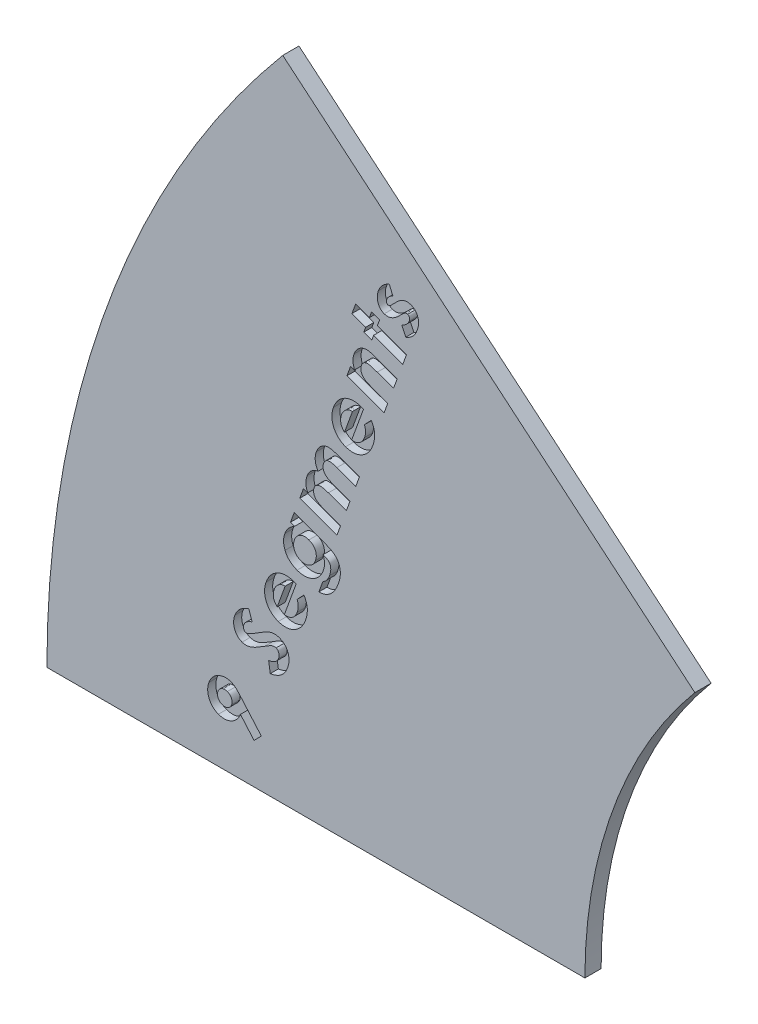
from build123d import *

# Parameters (mm, degrees)
BOSS_EXTRUDE1_DEPTH = 3.175
CUT_EXTRUDE1_DEPTH  = 1.5875


with BuildPart() as part:
    # Sketch2 → Boss-Extrude1 (new body)
    with BuildSketch(Plane.XY):
        with BuildLine():
            Line((0, 0), (105.445292337, 0))
            ThreePointArc((105.445292337, 0), (111.001509707, 31.510874554), (127, 59.221072586))
            Line((127, 59.221072586), (46.224219752, 127))
            ThreePointArc((46.224219752, 127), (11.915346601, 67.575288552), (0, 0))
        make_face()
    extrude(amount=BOSS_EXTRUDE1_DEPTH)

    # Sketch3 → Cut-Extrude1 (cut)
    with BuildSketch(Plane.XY.offset(3.175)):
        with BuildLine():
            Line((42.016640282, 9.353258219), (40.594080854, 7.907378144))
            Line((40.594080854, 7.907378144), (37.929166991, 10.998423817))
            add(Edge.make_bspline(
                [(37.929166991, 10.998423817), (37.885853294, 10.888052491), (37.800373976, 10.670235353), (37.640916121, 10.362599517), (37.457053629, 10.078450819), (37.251121295, 9.816696228), (37.021085541, 9.57706123), (36.76475112, 9.363872684), (36.489120282, 9.168725945), (36.190861614, 9.00395088), (35.882115791, 8.862940332), (35.565303011, 8.75964719), (35.246619215, 8.688348741), (34.924652519, 8.651588221), (34.599030785, 8.652339189), (34.271074005, 8.687073033), (33.940022624, 8.753610882), (33.724410797, 8.826490691), (33.614847413, 8.863524645)],
                knots=[0, 0, 0, 0, 1.060142226, 2.092184197, 3.093464805, 4.083768351, 5.067390293, 6.058964299, 7.062159022, 8.083926241, 9.10261829, 10.094212449, 11.059004012, 12.019644129, 12.986897348, 13.965712959, 14.96627483, 16, 16, 16, 16], degree=3))
            add(Edge.make_bspline(
                [(33.614847413, 8.863524645), (33.509909072, 8.905054064), (33.303708371, 8.98665813), (33.015851438, 9.147038077), (32.748546487, 9.328009847), (32.509117873, 9.540469163), (32.289216607, 9.774993556), (32.09790083, 10.039326863), (31.926293982, 10.327577576), (31.782497061, 10.639302618), (31.664263966, 10.96388452), (31.578992669, 11.295522547), (31.524782767, 11.629063243), (31.50732832, 11.96569384), (31.516436512, 12.305070161), (31.562591108, 12.646197659), (31.637906157, 12.990945727), (31.714461397, 13.21594227), (31.753435822, 13.330488454)],
                knots=[0, 0, 0, 0, 1.005324294, 1.975432156, 2.931522168, 3.878200568, 4.8234938, 5.79270076, 6.781537987, 7.810519289, 8.84902662, 9.857741961, 10.859525012, 11.85675931, 12.85917635, 13.882294683, 14.92187205, 16, 16, 16, 16], degree=3))
            add(Edge.make_bspline(
                [(31.753435822, 13.330488454), (31.799436173, 13.447986083), (31.889820439, 13.678852514), (32.058190472, 14.004020708), (32.250598507, 14.302919462), (32.463993268, 14.577786905), (32.704218665, 14.824831167), (32.964786943, 15.048908391), (33.251277415, 15.244424513), (33.55632997, 15.412318188), (33.872464727, 15.550899032), (34.189603596, 15.660674147), (34.506136651, 15.732794343), (34.819163255, 15.773413086), (35.130594906, 15.78368134), (35.438813247, 15.754092954), (35.745778467, 15.696226726), (35.94400992, 15.630253543), (36.044434753, 15.596831269)],
                knots=[0, 0, 0, 0, 1.123558795, 2.207636099, 3.255458764, 4.286925767, 5.302085954, 6.320248139, 7.34357485, 8.386183254, 9.417919214, 10.415374452, 11.371417735, 12.304592384, 13.2241177, 14.140663916, 15.058053032, 16, 16, 16, 16], degree=3))
            add(Edge.make_bspline(
                [(36.044434753, 15.596831269), (36.119931662, 15.567796927), (36.270991801, 15.509702737), (36.489011915, 15.397136905), (36.699803876, 15.266097405), (36.871922448, 15.140573104), (37.013198151, 15.02465813), (37.13166885, 14.918925881), (37.259232846, 14.793349334), (37.401530288, 14.653557778), (37.549403178, 14.49130639), (37.714380922, 14.316179344), (37.887804925, 14.120666964), (38.005707029, 13.982946346), (38.066970811, 13.911384554)],
                knots=[0, 0, 0, 0, 1.091979601, 2.184918487, 3.30812201, 4.442305933, 5.05956538, 5.776225361, 6.586354439, 7.47737268, 8.47021682, 9.550998054, 10.727460196, 12, 12, 12, 12], degree=3))
            Line((38.066970811, 13.911384554), (42.016640282, 9.353258219))
        make_face()
        with BuildLine():
            add(Edge.make_bspline(
                [(36.199199043, 11.759524912), (36.228657185, 11.852668486), (36.285975363, 12.033902592), (36.30329388, 12.316656177), (36.268021767, 12.593259115), (36.172123254, 12.856648993), (36.03594766, 13.100426231), (35.850048383, 13.305844901), (35.626631627, 13.474734378), (35.452822042, 13.546207614), (35.363895891, 13.582775446)],
                knots=[0, 0, 0, 0, 1.045045202, 2.033396657, 3.012743776, 4.01783249, 5.023493383, 5.990337497, 6.971796924, 8, 8, 8, 8], degree=3))
            add(Edge.make_bspline(
                [(35.363895891, 13.582775446), (35.269375692, 13.612592235), (35.085430825, 13.670618406), (34.797628893, 13.682942264), (34.516082016, 13.640636353), (34.247940492, 13.537600332), (34.003370257, 13.39133848), (33.79538307, 13.205227362), (33.626767978, 12.984536852), (33.555485711, 12.814409601), (33.519444769, 12.728391766)],
                knots=[0, 0, 0, 0, 1.049889721, 2.043180471, 3.031541709, 4.058786779, 5.076866243, 6.045375139, 7.011724462, 8, 8, 8, 8], degree=3))
            add(Edge.make_bspline(
                [(33.519444769, 12.728391766), (33.491150103, 12.635188238), (33.435415149, 12.451595535), (33.414160546, 12.164872727), (33.452653423, 11.881750564), (33.540413494, 11.607926075), (33.678679054, 11.35575292), (33.86573843, 11.141553473), (34.093902993, 10.965954117), (34.27207089, 10.892064483), (34.363228156, 10.854259821)],
                knots=[0, 0, 0, 0, 1.019895558, 2.008994586, 2.98862379, 4.001756578, 5.010891699, 5.983393364, 6.968229675, 8, 8, 8, 8], degree=3))
            add(Edge.make_bspline(
                [(34.363228156, 10.854259821), (34.456394513, 10.825545158), (34.637793974, 10.769636303), (34.920736925, 10.753858956), (35.19762686, 10.794039152), (35.462098006, 10.895749164), (35.705651974, 11.044876979), (35.915105225, 11.241453637), (36.084722562, 11.481951649), (36.160281993, 11.665162014), (36.199199043, 11.759524912)],
                knots=[0, 0, 0, 0, 1.020023146, 1.986035024, 2.945791188, 3.936264358, 4.938662057, 5.925128351, 6.931332828, 8, 8, 8, 8], degree=3))
        make_face(mode=Mode.SUBTRACT)
        with BuildLine():
            Line((39.540130815, 29.786140957), (40.216429559, 27.83144678))
            add(Edge.make_bspline(
                [(40.216429559, 27.83144678), (40.11199429, 27.795471087), (39.911810136, 27.726511972), (39.630983878, 27.603156586), (39.383022339, 27.465503807), (39.163483258, 27.316935746), (38.976312636, 27.154335959), (38.82080389, 26.977675751), (38.695280761, 26.789120032), (38.637781835, 26.652318707), (38.609425019, 26.584852229)],
                knots=[0, 0, 0, 0, 1.259249042, 2.413760288, 3.492341546, 4.489258686, 5.431557168, 6.310935981, 7.167002213, 8, 8, 8, 8], degree=3))
            add(Edge.make_bspline(
                [(38.609425019, 26.584852229), (38.588203781, 26.520364373), (38.547325167, 26.396140982), (38.522521021, 26.206864192), (38.525038738, 26.026129965), (38.561027017, 25.85814419), (38.621489249, 25.710337042), (38.700909257, 25.587726466), (38.799025407, 25.491494366), (38.879441038, 25.45555795), (38.918953598, 25.437900439)],
                knots=[0, 0, 0, 0, 1.242797265, 2.394008739, 3.483124416, 4.543237651, 5.525359634, 6.395359241, 7.211552972, 8, 8, 8, 8], degree=3))
            add(Edge.make_bspline(
                [(38.918953598, 25.437900439), (38.961039688, 25.425639308), (39.04540398, 25.401061077), (39.179350266, 25.394137423), (39.317703919, 25.408759618), (39.408325764, 25.436324009), (39.455328464, 25.450620792)],
                knots=[0, 0, 0, 0, 0.959855315, 1.924092125, 2.923291887, 4, 4, 4, 4], degree=3))
            add(Edge.make_bspline(
                [(39.455328464, 25.450620792), (39.492969316, 25.465743354), (39.580188932, 25.500784647), (39.724759362, 25.572677772), (39.90113932, 25.668574699), (40.112282851, 25.784473583), (40.352706165, 25.928542017), (40.629391718, 26.090218186), (40.935842979, 26.279838444), (41.150737961, 26.414433728), (41.263738587, 26.485209467)],
                knots=[0, 0, 0, 0, 0.466706266, 1.081429856, 1.85645288, 2.777524465, 3.852950597, 5.081778915, 6.465479248, 8, 8, 8, 8], degree=3))
            add(Edge.make_bspline(
                [(41.263738587, 26.485209467), (41.368224427, 26.551802526), (41.56695991, 26.678464702), (41.850805086, 26.855815382), (42.103221578, 27.01364323), (42.325097476, 27.148219441), (42.515106963, 27.263560089), (42.672568188, 27.358960927), (42.800294388, 27.43225247), (42.876280585, 27.471252954), (42.908904185, 27.487997261)],
                knots=[0, 0, 0, 0, 1.543054767, 2.934940615, 4.168235638, 5.25046588, 6.166652502, 6.936420986, 7.543367375, 8, 8, 8, 8], degree=3))
            add(Edge.make_bspline(
                [(42.908904185, 27.487997261), (43.038158081, 27.550445552), (43.285475014, 27.669935334), (43.652006682, 27.814791072), (43.997740537, 27.910478319), (44.323557173, 27.969375717), (44.639839936, 27.983644646), (44.951924246, 27.962081429), (45.265666436, 27.905804603), (45.468511082, 27.838250655), (45.571697989, 27.803886016)],
                knots=[0, 0, 0, 0, 1.244426712, 2.38111042, 3.411264158, 4.350053435, 5.24562082, 6.148369224, 7.058076926, 8, 8, 8, 8], degree=3))
            add(Edge.make_bspline(
                [(45.571697989, 27.803886016), (45.66950539, 27.76579356), (45.862003216, 27.690822597), (46.129793772, 27.542254847), (46.375427075, 27.372419433), (46.597411915, 27.178271927), (46.795503488, 26.960471073), (46.971373681, 26.719657777), (47.118658808, 26.451924091), (47.245495962, 26.165753111), (47.345333044, 25.863449164), (47.412684971, 25.549931501), (47.451509266, 25.228445023), (47.457466496, 24.898210939), (47.430836086, 24.559934661), (47.37539567, 24.213170998), (47.288647509, 23.857709799), (47.207483896, 23.622538092), (47.165982177, 23.502286791)],
                knots=[0, 0, 0, 0, 0.979291508, 1.927374458, 2.851919103, 3.763941763, 4.674913154, 5.596343256, 6.541850014, 7.522874586, 8.51629674, 9.50917069, 10.512778253, 11.535920654, 12.588254492, 13.677602042, 14.812478839, 16, 16, 16, 16], degree=3))
            add(Edge.make_bspline(
                [(47.165982177, 23.502286791), (47.130293398, 23.409275086), (47.059711607, 23.225325598), (46.936991399, 22.960928768), (46.800824489, 22.711745196), (46.652159182, 22.477975125), (46.490904205, 22.258267783), (46.315128443, 22.055464634), (46.126821056, 21.867639134), (45.927407631, 21.692782316), (45.713062668, 21.533227866), (45.481786666, 21.390747639), (45.235581484, 21.262086236), (44.975166521, 21.144374145), (44.697283605, 21.045649174), (44.405186747, 20.958675446), (44.096613343, 20.885845568), (43.884371812, 20.850949568), (43.776008218, 20.833132811)],
                knots=[0, 0, 0, 0, 1.048014307, 2.072660601, 3.064291067, 4.033790116, 4.9855911, 5.929224471, 6.85460551, 7.782134993, 8.71755899, 9.662597537, 10.637130615, 11.638995355, 12.66687415, 13.73733354, 14.844756408, 16, 16, 16, 16], degree=3))
            Line((43.776008218, 20.833132811), (43.449519169, 22.891709868))
            add(Edge.make_bspline(
                [(43.449519169, 22.891709868), (43.575900632, 22.917620493), (43.81861374, 22.967381338), (44.158958454, 23.076672022), (44.462960265, 23.204498804), (44.728151371, 23.357491078), (44.955872537, 23.53276474), (45.147693679, 23.728560353), (45.30042987, 23.950083788), (45.36813642, 24.11355852), (45.402093288, 24.195546005)],
                knots=[0, 0, 0, 0, 1.25802725, 2.416016549, 3.481716423, 4.470460391, 5.394574196, 6.2772384, 7.135983337, 8, 8, 8, 8], degree=3))
            add(Edge.make_bspline(
                [(45.402093288, 24.195546005), (45.429590031, 24.281072798), (45.482856501, 24.446754619), (45.515310281, 24.700719702), (45.502909195, 24.946370794), (45.447192582, 25.177368015), (45.361279689, 25.386141926), (45.243882851, 25.559536013), (45.097733745, 25.695519303), (44.979988405, 25.747005855), (44.920839949, 25.772869723)],
                knots=[0, 0, 0, 0, 1.18285366, 2.291414673, 3.355318235, 4.408720333, 5.410955289, 6.315723653, 7.153916876, 8, 8, 8, 8], degree=3))
            add(Edge.make_bspline(
                [(44.920839949, 25.772869723), (44.864079127, 25.790353483), (44.747564098, 25.826243039), (44.558134286, 25.830066642), (44.358181049, 25.806756258), (44.183899155, 25.757630313), (44.030851539, 25.699150229), (43.895908415, 25.636322956), (43.740021423, 25.560601883), (43.567925113, 25.464409273), (43.376742268, 25.353592696), (43.165730706, 25.228863145), (42.938447132, 25.084454013), (42.780904653, 24.982223152), (42.699018368, 24.929086337)],
                knots=[0, 0, 0, 0, 0.867842592, 1.78145243, 2.752699461, 3.816950524, 4.42753279, 5.156254102, 6.000410368, 6.970493863, 8.048502387, 9.243760348, 10.567381771, 12, 12, 12, 12], degree=3))
            add(Edge.make_bspline(
                [(42.699018368, 24.929086337), (42.542574916, 24.828035039), (42.241962247, 24.633860722), (41.802581516, 24.365770733), (41.399164769, 24.12482977), (41.027145327, 23.918645613), (40.688313884, 23.743427894), (40.38072184, 23.602075147), (40.107920141, 23.486250142), (39.861065467, 23.406915462), (39.63438951, 23.349498433), (39.41811405, 23.312070176), (39.207895386, 23.287376804), (39.003729913, 23.281758449), (38.805092417, 23.289077797), (38.612446773, 23.31553308), (38.424474584, 23.354123838), (38.304486761, 23.39501495), (38.244774912, 23.415364382)],
                knots=[0, 0, 0, 0, 1.835047382, 3.526120678, 5.071448161, 6.464707309, 7.716637059, 8.828898001, 9.80002765, 10.63461198, 11.381086898, 12.102321897, 12.795934574, 13.464741248, 14.112930305, 14.752079676, 15.378973397, 16, 16, 16, 16], degree=3))
            add(Edge.make_bspline(
                [(38.244774912, 23.415364382), (38.161793105, 23.447865505), (37.997646975, 23.512155907), (37.770807017, 23.645060963), (37.558052641, 23.794694339), (37.367677125, 23.972498057), (37.194220963, 24.170848138), (37.041061186, 24.392992035), (36.907766336, 24.638797071), (36.792023902, 24.903755412), (36.69897367, 25.182361621), (36.635963222, 25.469602733), (36.59620158, 25.75962822), (36.58952015, 26.055037164), (36.605542222, 26.353764797), (36.651319301, 26.656512155), (36.722793191, 26.963171749), (36.791489659, 27.164855677), (36.826455601, 27.26751115)],
                knots=[0, 0, 0, 0, 0.936448395, 1.852386499, 2.758368459, 3.668825935, 4.585970809, 5.526632219, 6.501760602, 7.524148564, 8.56593373, 9.587103903, 10.614671551, 11.641350801, 12.691595158, 13.759074909, 14.859387433, 16, 16, 16, 16], degree=3))
            add(Edge.make_bspline(
                [(36.826455601, 27.26751115), (36.878467952, 27.398289994), (36.981882506, 27.658313544), (37.192058771, 28.022017277), (37.435534199, 28.362796674), (37.672269929, 28.625069393), (37.886061853, 28.821964994), (38.066952956, 28.968057225), (38.265755285, 29.111808792), (38.484329996, 29.252264888), (38.720284566, 29.391334414), (38.97588081, 29.528094771), (39.251789626, 29.657827476), (39.44245465, 29.742674505), (39.540130815, 29.786140957)],
                knots=[0, 0, 0, 0, 1.324407864, 2.633279368, 3.945110688, 5.264908753, 5.952810712, 6.681696361, 7.454100858, 8.262946113, 9.12844321, 10.033886327, 10.992775721, 12, 12, 12, 12], degree=3))
        make_face()
        with BuildLine():
            Line((48.859189563, 38.611004947), (46.533485103, 32.221147842))
            add(Edge.make_bspline(
                [(46.533485103, 32.221147842), (46.601183558, 32.210576043), (46.735328169, 32.189628003), (46.936324255, 32.18276878), (47.132249892, 32.189905597), (47.323308142, 32.218160345), (47.509215991, 32.264756833), (47.690691869, 32.329135041), (47.867923595, 32.409730386), (48.039119426, 32.510017999), (48.20390715, 32.625233634), (48.357837318, 32.75886967), (48.502117479, 32.906327559), (48.633203567, 33.071894202), (48.757965891, 33.249404225), (48.866271732, 33.446407461), (48.969976019, 33.65531628), (49.025816757, 33.803580068), (49.054234969, 33.879033793)],
                knots=[0, 0, 0, 0, 0.994573682, 1.970749532, 2.916154219, 3.839563181, 4.77081464, 5.696218932, 6.633393545, 7.594827866, 8.574667891, 9.55014167, 10.552053531, 11.566978119, 12.614959783, 13.699904295, 14.829445872, 16, 16, 16, 16], degree=3))
            add(Edge.make_bspline(
                [(49.054234969, 33.879033793), (49.08580358, 33.971068484), (49.147937344, 34.1522124), (49.207614525, 34.430495893), (49.247582788, 34.705964393), (49.258384911, 34.980978432), (49.239992395, 35.253315127), (49.20079986, 35.524070629), (49.132328088, 35.79306971), (49.067828143, 35.967814012), (49.03515444, 36.05633414)],
                knots=[0, 0, 0, 0, 1.046916631, 2.060555376, 3.059315428, 4.04176404, 5.01776603, 5.995013338, 6.984334974, 8, 8, 8, 8], degree=3))
            Line((49.03515444, 36.05633414), (50.368671401, 37.468293275))
            add(Edge.make_bspline(
                [(50.368671401, 37.468293275), (50.416280629, 37.391119101), (50.510370409, 37.238600331), (50.633152525, 37.002533568), (50.739586996, 36.763785378), (50.831179679, 36.522678646), (50.905253054, 36.277378338), (50.965052668, 36.029804368), (51.007651781, 35.779043093), (51.032451988, 35.525428847), (51.043932485, 35.267739563), (51.036291902, 35.00442624), (51.016045317, 34.73531016), (50.976411094, 34.460998209), (50.924168287, 34.180500453), (50.852753789, 33.894488368), (50.769453856, 33.601624113), (50.700478214, 33.407325885), (50.665479627, 33.308737987)],
                knots=[0, 0, 0, 0, 1.003372104, 1.982957145, 2.94231701, 3.89531061, 4.835539966, 5.776517304, 6.712638414, 7.648138463, 8.595369071, 9.565540841, 10.561968475, 11.580740041, 12.631555505, 13.718571656, 14.842391789, 16, 16, 16, 16], degree=3))
            add(Edge.make_bspline(
                [(50.665479627, 33.308737987), (50.607116465, 33.157889875), (50.49285057, 32.862552992), (50.283806875, 32.445226001), (50.048165257, 32.062195804), (49.786739513, 31.712609039), (49.499448631, 31.397046913), (49.186285284, 31.115722683), (48.847153281, 30.867835328), (48.484023241, 30.657659721), (48.106919957, 30.484816254), (47.72332244, 30.350957335), (47.334841323, 30.263961754), (46.942534943, 30.219009091), (46.546537725, 30.21690107), (46.147474727, 30.258544021), (45.743849331, 30.339818747), (45.480397274, 30.428874054), (45.346252197, 30.474219424)],
                knots=[0, 0, 0, 0, 1.14956424, 2.250666018, 3.313271713, 4.343350035, 5.349923679, 6.342656435, 7.331617919, 8.331332958, 9.3206518, 10.277260766, 11.21468722, 12.145247375, 13.07986853, 14.024338612, 14.994028538, 16, 16, 16, 16], degree=3))
            add(Edge.make_bspline(
                [(45.346252197, 30.474219424), (45.211634348, 30.527664324), (44.947088773, 30.632692091), (44.574103719, 30.828753312), (44.232290706, 31.0560585), (43.924411453, 31.317023349), (43.643543342, 31.604030806), (43.397144987, 31.924169833), (43.182473306, 32.27439298), (42.99914381, 32.649873446), (42.851487513, 33.04301575), (42.744792903, 33.446556928), (42.678728439, 33.856272155), (42.65281081, 34.271735003), (42.670904722, 34.693511441), (42.729273151, 35.120398365), (42.825164957, 35.554773552), (42.922364808, 35.83948811), (42.971786385, 35.984252143)],
                knots=[0, 0, 0, 0, 1.035745248, 2.035404844, 3.008629504, 3.966764085, 4.917895653, 5.876657063, 6.850511965, 7.85226643, 8.861850596, 9.850348795, 10.833712846, 11.826585095, 12.823478881, 13.84890462, 14.906268642, 16, 16, 16, 16], degree=3))
            add(Edge.make_bspline(
                [(42.971786385, 35.984252143), (43.030817092, 36.135840544), (43.146414002, 36.432688603), (43.357698434, 36.850874968), (43.592809621, 37.236480273), (43.859421825, 37.583873108), (44.148464405, 37.900948056), (44.46544466, 38.181587221), (44.809412193, 38.427393046), (45.177349095, 38.6354225), (45.561609052, 38.809134749), (45.960121503, 38.932688416), (46.365974879, 39.018431533), (46.780826086, 39.052130204), (47.204353549, 39.047191341), (47.635886975, 38.991716036), (48.077123556, 38.895131534), (48.367450805, 38.79687486), (48.515740044, 38.746688708)],
                knots=[0, 0, 0, 0, 1.119851808, 2.192950341, 3.222227994, 4.225869297, 5.204158979, 6.173019876, 7.136007014, 8.110378112, 9.079972254, 10.034360238, 10.978403633, 11.931102258, 12.894913139, 13.890413649, 14.922495378, 16, 16, 16, 16], degree=3))
            Line((48.515740044, 38.746688708), (48.859189563, 38.611004947))
        make_face()
        with BuildLine():
            add(Edge.make_bspline(
                [(46.694609568, 37.137564108), (46.583269128, 37.136807545), (46.360732598, 37.1352954), (46.03195579, 37.057226777), (45.716047196, 36.919742019), (45.414426556, 36.730380364), (45.140523641, 36.488470189), (44.899891636, 36.204919345), (44.69754894, 35.880201073), (44.600710324, 35.640377988), (44.551230161, 35.517839215)],
                knots=[0, 0, 0, 0, 0.928225838, 1.855248239, 2.79986588, 3.797837544, 4.819081038, 5.841553548, 6.89713127, 8, 8, 8, 8], degree=3))
            add(Edge.make_bspline(
                [(44.551230161, 35.517839215), (44.507547925, 35.381035174), (44.422332839, 35.114158537), (44.365715628, 34.702956631), (44.36859988, 34.297396671), (44.422525377, 34.035381231), (44.449467341, 33.904474498)],
                knots=[0, 0, 0, 0, 1.049111874, 2.046602168, 3.024053971, 4, 4, 4, 4], degree=3))
            add(Edge.make_bspline(
                [(44.449467341, 33.904474498), (44.476157037, 33.819092056), (44.532571637, 33.638617306), (44.686698022, 33.377932509), (44.879710743, 33.099985406), (45.042070768, 32.92448532), (45.127886144, 32.831724765)],
                knots=[0, 0, 0, 0, 0.834963261, 1.764880242, 2.818627648, 4, 4, 4, 4], degree=3))
            Line((45.127886144, 32.831724765), (46.694609568, 37.137564108))
        make_face(mode=Mode.SUBTRACT)
        with BuildLine():
            Line((47.742153162, 48.512783712), (48.465093199, 50.495038653))
            Line((48.465093199, 50.495038653), (54.702306073, 48.224455721))
            add(Edge.make_bspline(
                [(54.702306073, 48.224455721), (54.850006152, 48.167525485), (55.136082693, 48.057258755), (55.539902945, 47.868953553), (55.903374976, 47.665449042), (56.22821479, 47.449708447), (56.512410727, 47.217509246), (56.757843071, 46.971218413), (56.965138778, 46.710347757), (57.071324865, 46.521434893), (57.123413178, 46.42876595)],
                knots=[0, 0, 0, 0, 1.231771816, 2.385787621, 3.464410197, 4.47123999, 5.417057756, 6.315484882, 7.173681294, 8, 8, 8, 8], degree=3))
            add(Edge.make_bspline(
                [(57.123413178, 46.42876595), (57.184313652, 46.300174326), (57.306466176, 46.042248722), (57.424268023, 45.626442533), (57.497522678, 45.192062003), (57.519257788, 44.736864628), (57.4934338, 44.260867906), (57.414226033, 43.76534509), (57.289507072, 43.248168508), (57.171509282, 42.902950046), (57.110692825, 42.725023296)],
                knots=[0, 0, 0, 0, 0.894278086, 1.793718821, 2.709294308, 3.662479538, 4.655877576, 5.704621255, 6.816954112, 8, 8, 8, 8], degree=3))
            add(Edge.make_bspline(
                [(57.110692825, 42.725023296), (57.039831849, 42.539467373), (56.903541259, 42.182578047), (56.665141727, 41.686323619), (56.41499036, 41.245268435), (56.140841017, 40.864603964), (55.849942403, 40.533230786), (55.538422096, 40.24803367), (55.209621831, 40.001618487), (54.858832934, 39.801424571), (54.491555056, 39.64315344), (54.106944438, 39.532770961), (53.706749781, 39.467218445), (53.434759147, 39.461112095), (53.296707115, 39.458012745)],
                knots=[0, 0, 0, 0, 1.325632118, 2.549656986, 3.672139062, 4.706591996, 5.67598677, 6.611013914, 7.521652079, 8.413542238, 9.301341968, 10.185359773, 11.078958093, 12, 12, 12, 12], degree=3))
            Line((53.296707115, 39.458012745), (54.095969268, 41.652273563))
            add(Edge.make_bspline(
                [(54.095969268, 41.652273563), (54.164111388, 41.68512459), (54.301923127, 41.751563045), (54.493164266, 41.886070319), (54.674335079, 42.045492817), (54.842828523, 42.234676006), (54.998697252, 42.451216744), (55.143808056, 42.694990245), (55.275197071, 42.966893267), (55.348994991, 43.161139765), (55.387085053, 43.261398162)],
                knots=[0, 0, 0, 0, 0.85471919, 1.728598068, 2.635014789, 3.580615043, 4.588246214, 5.649646736, 6.786888545, 8, 8, 8, 8], degree=3))
            add(Edge.make_bspline(
                [(55.387085053, 43.261398162), (55.431078437, 43.38931364), (55.514953234, 43.633188594), (55.598915991, 43.992310474), (55.639449068, 44.323783592), (55.636203629, 44.626926089), (55.594757534, 44.899844146), (55.529796066, 45.144883609), (55.428527163, 45.3584508), (55.317935106, 45.514164661), (55.209015396, 45.626469294), (55.107191419, 45.707820876), (54.986682964, 45.787590224), (54.851247301, 45.872270826), (54.693256994, 45.949992949), (54.520078471, 46.03440129), (54.32619621, 46.114007434), (54.190103595, 46.164859359), (54.119289914, 46.191319369)],
                knots=[0, 0, 0, 0, 1.736012843, 3.30976407, 4.725633788, 6.014221972, 7.188376626, 8.262753707, 9.257137946, 10.20645318, 10.70053068, 11.261705852, 11.875772439, 12.555813193, 13.310619944, 14.134526689, 15.029329898, 16, 16, 16, 16], degree=3))
            add(Edge.make_bspline(
                [(54.119289914, 46.191319369), (54.163840966, 46.076157231), (54.250658858, 45.85173752), (54.342490527, 45.508743171), (54.398230636, 45.172113518), (54.417566963, 44.838119004), (54.402259801, 44.503562231), (54.352067096, 44.162392761), (54.269667511, 43.811009698), (54.189900074, 43.578081188), (54.148970737, 43.458563627)],
                knots=[0, 0, 0, 0, 1.056205475, 2.058257426, 3.032695452, 3.971747255, 4.916217662, 5.893878838, 6.919331661, 8, 8, 8, 8], degree=3))
            add(Edge.make_bspline(
                [(54.148970737, 43.458563627), (54.09832386, 43.328919979), (53.998653334, 43.07378775), (53.810962042, 42.714439233), (53.594903298, 42.384210002), (53.355360848, 42.078211294), (53.084442432, 41.801918339), (52.786361084, 41.553429341), (52.461856307, 41.330788316), (52.112447829, 41.140734603), (51.748652597, 40.981102122), (51.374608839, 40.863792597), (50.995887613, 40.787020062), (50.611427173, 40.750718937), (50.222069111, 40.75538652), (49.827796464, 40.800248701), (49.428639325, 40.887520071), (49.166803058, 40.975584166), (49.033268947, 41.020496052)],
                knots=[0, 0, 0, 0, 1.0545608, 2.075323036, 3.066427534, 4.042828306, 5.01644741, 5.993891103, 6.980555133, 7.994716814, 9.00486621, 9.987595518, 10.960492149, 11.92908708, 12.909521159, 13.906975996, 14.932576825, 16, 16, 16, 16], degree=3))
            add(Edge.make_bspline(
                [(49.033268947, 41.020496052), (48.893523325, 41.0749745), (48.619663668, 41.181735978), (48.237364384, 41.385816379), (47.88668408, 41.613802025), (47.573598543, 41.874763823), (47.293112969, 42.16240023), (47.048931302, 42.479866754), (46.837722407, 42.825694801), (46.728793725, 43.074133093), (46.673643546, 43.199916458)],
                knots=[0, 0, 0, 0, 1.085603759, 2.127458938, 3.132640721, 4.110510174, 5.073433779, 6.03690147, 7.006090661, 8, 8, 8, 8], degree=3))
            add(Edge.make_bspline(
                [(46.673643546, 43.199916458), (46.629578681, 43.316454765), (46.542685149, 43.546262009), (46.45445433, 43.901930152), (46.398727334, 44.258810521), (46.377526848, 44.618043275), (46.390436979, 44.978632012), (46.437608634, 45.341318494), (46.519597521, 45.706360766), (46.600774867, 45.9453372), (46.641842665, 46.066235902)],
                knots=[0, 0, 0, 0, 1.018217582, 2.007870038, 2.990408693, 3.968876167, 4.946250571, 5.936982551, 6.956314946, 8, 8, 8, 8], degree=3))
            add(Edge.make_bspline(
                [(46.641842665, 46.066235902), (46.685864691, 46.17802087), (46.772758635, 46.398670343), (46.935494528, 46.712804107), (47.124593533, 47.005215323), (47.339235514, 47.280727009), (47.585678775, 47.540748406), (47.87098021, 47.782373678), (48.191084043, 48.014640231), (48.424903785, 48.150205542), (48.545655432, 48.220215603)],
                knots=[0, 0, 0, 0, 0.979532632, 1.933474269, 2.880072405, 3.816417094, 4.778699951, 5.796612462, 6.862103471, 8, 8, 8, 8], degree=3))
            Line((48.545655432, 48.220215603), (47.742153162, 48.512783712))
        make_face()
        with BuildLine():
            add(Edge.make_bspline(
                [(48.509614433, 45.896631202), (48.483630637, 45.819277252), (48.432693583, 45.667637271), (48.37874534, 45.43718762), (48.350424623, 45.210519574), (48.337918144, 44.987834363), (48.35083486, 44.768091886), (48.387809441, 44.552616243), (48.442635986, 44.339803978), (48.52087264, 44.134022179), (48.618364987, 43.937951284), (48.730466373, 43.753202244), (48.862503123, 43.58633437), (49.009196168, 43.434547473), (49.172905772, 43.300086722), (49.350844645, 43.178639432), (49.546935725, 43.073702034), (49.687019327, 43.019660569), (49.758329043, 42.992150699)],
                knots=[0, 0, 0, 0, 1.106775613, 2.169655636, 3.204311013, 4.202610033, 5.191843511, 6.183304785, 7.164701149, 8.169059424, 9.16385304, 10.132426304, 11.09528803, 12.044543966, 12.99103585, 13.964343127, 14.963746562, 16, 16, 16, 16], degree=3))
            add(Edge.make_bspline(
                [(49.758329043, 42.992150699), (49.83357768, 42.967607784), (49.981061816, 42.91950471), (50.204380167, 42.869431389), (50.424826599, 42.847219445), (50.642347633, 42.843079908), (50.856733445, 42.868271032), (51.069148937, 42.911648857), (51.276539795, 42.983336689), (51.480044289, 43.073776735), (51.674005186, 43.185445201), (51.854329905, 43.316350223), (52.024229743, 43.459393775), (52.173616624, 43.625223211), (52.313084645, 43.803272506), (52.435785222, 43.999711024), (52.54503546, 44.21228443), (52.603393319, 44.363235763), (52.633128723, 44.440150833)],
                knots=[0, 0, 0, 0, 1.053826395, 2.065455046, 3.040343215, 4.000353711, 4.956527571, 5.908988841, 6.882194717, 7.872184353, 8.871435586, 9.856087345, 10.837089146, 11.822819778, 12.822425512, 13.845979129, 14.9024498, 16, 16, 16, 16], degree=3))
            add(Edge.make_bspline(
                [(52.633128723, 44.440150833), (52.659498876, 44.516006647), (52.711340005, 44.665131721), (52.759686957, 44.892416061), (52.794294548, 45.114589734), (52.801764956, 45.334240044), (52.789681367, 45.550130795), (52.755074919, 45.762437855), (52.699999677, 45.970611853), (52.62342145, 46.173438), (52.529227583, 46.368220247), (52.414029913, 46.54964654), (52.279639644, 46.7154245), (52.128249232, 46.866700209), (51.95951394, 47.003714961), (51.771945878, 47.123881287), (51.567330846, 47.231580346), (51.421094061, 47.288129743), (51.346253055, 47.317070571)],
                knots=[0, 0, 0, 0, 1.087881836, 2.138668752, 3.145545516, 4.133271737, 5.112361169, 6.073323445, 7.044881308, 8.02734111, 9.008725524, 9.973692621, 10.934463774, 11.896619703, 12.870867364, 13.87555308, 14.912751377, 16, 16, 16, 16], degree=3))
            add(Edge.make_bspline(
                [(51.346253055, 47.317070571), (51.271787381, 47.342619619), (51.125417946, 47.392838726), (50.902112684, 47.440860859), (50.682720452, 47.467308321), (50.467419694, 47.46886212), (50.255544587, 47.450356814), (50.047192162, 47.407614954), (49.842403894, 47.341518638), (49.644224734, 47.251911873), (49.453987887, 47.14506679), (49.277080736, 47.018470609), (49.112201296, 46.87654807), (48.96415766, 46.713569986), (48.827488533, 46.53550939), (48.707255862, 46.338596124), (48.597121484, 46.126168839), (48.539227819, 45.974309361), (48.509614433, 45.896631202)],
                knots=[0, 0, 0, 0, 1.059504592, 2.082558038, 3.069512157, 4.03084726, 4.976985435, 5.928946053, 6.889102558, 7.869010039, 8.853574881, 9.822792988, 10.794251633, 11.777665717, 12.782763977, 13.812832729, 14.881234617, 16, 16, 16, 16], degree=3))
        make_face(mode=Mode.SUBTRACT)
        with BuildLine():
            Line((49.554333827, 53.490558485), (50.281513982, 55.485533779))
            Line((50.281513982, 55.485533779), (51.118937193, 55.180245318))
            add(Edge.make_bspline(
                [(51.118937193, 55.180245318), (51.067919263, 55.295957069), (50.967006692, 55.524832882), (50.856765565, 55.879343957), (50.787078641, 56.23627829), (50.751212958, 56.594918728), (50.759109743, 56.956031304), (50.802489601, 57.319262087), (50.8793904, 57.685735725), (50.960927168, 57.9250393), (51.002333961, 58.046564762)],
                knots=[0, 0, 0, 0, 1.028288006, 2.033935642, 3.012679406, 3.982976646, 4.960554463, 5.944721045, 6.956268304, 8, 8, 8, 8], degree=3))
            add(Edge.make_bspline(
                [(51.002333961, 58.046564762), (51.050157578, 58.166722888), (51.143709727, 58.401775178), (51.334189664, 58.725391921), (51.557429981, 59.016421822), (51.817282844, 59.271686234), (52.108733711, 59.489098261), (52.429610351, 59.664298768), (52.778780131, 59.795949982), (53.024687345, 59.846291288), (53.149953486, 59.871935355)],
                knots=[0, 0, 0, 0, 1.046694548, 2.047534857, 3.031455916, 4.011419467, 4.989523995, 5.968483107, 6.965136983, 8, 8, 8, 8], degree=3))
            add(Edge.make_bspline(
                [(53.149953486, 59.871935355), (53.075978432, 59.990294195), (52.930099721, 60.223697674), (52.770419185, 60.601890224), (52.653677616, 60.989762984), (52.588443155, 61.389549459), (52.571825304, 61.795957893), (52.602445389, 62.204679088), (52.676972508, 62.615330732), (52.765741699, 62.881198371), (52.810744084, 63.015982497)],
                knots=[0, 0, 0, 0, 1.018489013, 2.00845902, 2.988792736, 3.972724018, 4.959902161, 5.954011733, 6.962766804, 8, 8, 8, 8], degree=3))
            add(Edge.make_bspline(
                [(52.810744084, 63.015982497), (52.864461236, 63.151915558), (52.968986155, 63.41641938), (53.181310505, 63.77717735), (53.422730046, 64.100075549), (53.702739577, 64.374145487), (54.004934545, 64.60051673), (54.320275589, 64.778506909), (54.649972711, 64.896699221), (54.936514826, 64.950019051), (55.178141264, 64.960862549), (55.379507129, 64.951530461), (55.600047565, 64.92427893), (55.841505457, 64.886067074), (56.100022184, 64.821301451), (56.378863265, 64.745399657), (56.677313568, 64.652104993), (56.881490035, 64.579853396), (56.987259842, 64.542424805)],
                knots=[0, 0, 0, 0, 1.36799652, 2.661900684, 3.909741494, 5.136808909, 6.319717549, 7.44035461, 8.517193967, 9.587659503, 10.157872592, 10.78101912, 11.474404618, 12.239867154, 13.070415283, 13.970223662, 14.948512262, 16, 16, 16, 16], degree=3))
            Line((56.987259842, 64.542424805), (61.257058186, 62.988421733))
            Line((61.257058186, 62.988421733), (60.527757973, 60.984966204))
            Line((60.527757973, 60.984966204), (56.834615612, 62.329083459))
            add(Edge.make_bspline(
                [(56.834615612, 62.329083459), (56.735301777, 62.364696546), (56.545050163, 62.43291914), (56.266657037, 62.515304868), (56.010001923, 62.57958007), (55.774546004, 62.62570442), (55.558926981, 62.649457611), (55.36448263, 62.654733679), (55.190590281, 62.641287183), (55.036744439, 62.606684633), (54.898279943, 62.555286029), (54.772446812, 62.48584094), (54.655051519, 62.404148986), (54.54997991, 62.303278437), (54.452073655, 62.190241187), (54.367991885, 62.058371357), (54.290392181, 61.914400131), (54.249866276, 61.810170875), (54.229063395, 61.756667593)],
                knots=[0, 0, 0, 0, 1.654701512, 3.16984674, 4.551764057, 5.804045511, 6.930268805, 7.950345918, 8.851591831, 9.658376367, 10.416070624, 11.160099818, 11.907507047, 12.65252652, 13.438871095, 14.247481281, 15.100391724, 16, 16, 16, 16], degree=3))
            add(Edge.make_bspline(
                [(54.229063395, 61.756667593), (54.202696379, 61.672462622), (54.150707651, 61.506432864), (54.114053001, 61.249711758), (54.119743304, 60.994046969), (54.158596838, 60.742149396), (54.23775246, 60.500038149), (54.351828494, 60.272473067), (54.499410271, 60.060277257), (54.652971199, 59.898967925), (54.79718341, 59.775904046), (54.929002086, 59.685046803), (55.079266138, 59.591576132), (55.251070748, 59.499138753), (55.442691448, 59.406606846), (55.652206907, 59.309833012), (55.884025164, 59.218265874), (56.0451729, 59.157267513), (56.128636044, 59.125674671)],
                knots=[0, 0, 0, 0, 1.146283412, 2.260165335, 3.353999112, 4.461531045, 5.563059843, 6.652250512, 7.761306712, 8.912039584, 9.538079509, 10.223995043, 10.991670051, 11.838850353, 12.759561427, 13.759013511, 14.8393273, 16, 16, 16, 16], degree=3))
            Line((56.128636044, 59.125674671), (59.414727123, 57.92996153))
            Line((59.414727123, 57.92996153), (58.68542691, 55.926506001))
            Line((58.68542691, 55.926506001), (55.159769191, 57.209141552))
            add(Edge.make_bspline(
                [(55.159769191, 57.209141552), (55.080643251, 57.236762836), (54.928305647, 57.289940852), (54.707411818, 57.365947463), (54.500785162, 57.427173228), (54.30803655, 57.475592804), (54.131795937, 57.517089906), (53.969579602, 57.544544183), (53.823119543, 57.562294278), (53.65098646, 57.570725568), (53.454720542, 57.560747126), (53.235676992, 57.518746269), (53.037210775, 57.445105989), (52.860401777, 57.338543935), (52.704983484, 57.206752239), (52.570624348, 57.04771575), (52.458173592, 56.862871596), (52.402522852, 56.725952384), (52.374011979, 56.655806215)],
                knots=[0, 0, 0, 0, 1.241323671, 2.389864522, 3.459582737, 4.431871806, 5.333296203, 6.14032884, 6.867378085, 7.517080787, 8.691046707, 9.768723637, 10.808791626, 11.808634154, 12.811102955, 13.813571757, 14.87985357, 16, 16, 16, 16], degree=3))
            add(Edge.make_bspline(
                [(52.374011979, 56.655806215), (52.347117499, 56.573803696), (52.293966574, 56.411744056), (52.264824884, 56.158386291), (52.268002426, 55.905044752), (52.310601915, 55.653264642), (52.390878765, 55.409268494), (52.509833064, 55.178318887), (52.666060688, 54.96435904), (52.824373075, 54.79830841), (52.973990147, 54.672892484), (53.109735387, 54.580666807), (53.261682343, 54.483844084), (53.437009438, 54.392575802), (53.629359048, 54.296541528), (53.842301659, 54.201224935), (54.075079084, 54.106184352), (54.238074394, 54.045557963), (54.32234598, 54.014212999)],
                knots=[0, 0, 0, 0, 1.109784494, 2.193240858, 3.268202408, 4.367319984, 5.470506147, 6.566335263, 7.70143567, 8.873927448, 9.51418687, 10.214123146, 10.987490908, 11.835123208, 12.759807799, 13.758636686, 14.841173763, 16, 16, 16, 16], degree=3))
            Line((54.32234598, 54.014212999), (57.561795767, 52.835460328))
            Line((57.561795767, 52.835460328), (56.834615612, 50.840485035))
            Line((56.834615612, 50.840485035), (49.554333827, 53.490558485))
        make_face()
        with BuildLine():
            Line((62.052580051, 74.859547399), (59.726875591, 68.469690295))
            add(Edge.make_bspline(
                [(59.726875591, 68.469690295), (59.794574046, 68.459118495), (59.928718658, 68.438170456), (60.129714744, 68.431311232), (60.32564038, 68.43844805), (60.51669863, 68.466702797), (60.70260648, 68.513299285), (60.884082357, 68.577677493), (61.061314083, 68.658272839), (61.232509914, 68.758560451), (61.397297638, 68.873776086), (61.551227807, 69.007412122), (61.695507968, 69.154870011), (61.826594055, 69.320436654), (61.951356379, 69.497946678), (62.05966222, 69.694949913), (62.163366507, 69.903858733), (62.219207246, 70.052122521), (62.247625457, 70.127576246)],
                knots=[0, 0, 0, 0, 0.994573682, 1.970749532, 2.916154219, 3.839563181, 4.77081464, 5.696218932, 6.633393545, 7.594827866, 8.574667891, 9.55014167, 10.552053531, 11.566978119, 12.614959783, 13.699904295, 14.829445872, 16, 16, 16, 16], degree=3))
            add(Edge.make_bspline(
                [(62.247625457, 70.127576246), (62.279194068, 70.219610937), (62.341327833, 70.400754852), (62.401005013, 70.679038346), (62.440973276, 70.954506845), (62.4517754, 71.229520884), (62.433382883, 71.50185758), (62.394190348, 71.772613081), (62.325718577, 72.041612162), (62.261218631, 72.216356464), (62.228544928, 72.304876593)],
                knots=[0, 0, 0, 0, 1.046916631, 2.060555376, 3.059315428, 4.04176404, 5.01776603, 5.995013338, 6.984334974, 8, 8, 8, 8], degree=3))
            Line((62.228544928, 72.304876593), (63.562061889, 73.716835727))
            add(Edge.make_bspline(
                [(63.562061889, 73.716835727), (63.609671117, 73.639661553), (63.703760897, 73.487142783), (63.826543013, 73.25107602), (63.932977484, 73.01232783), (64.024570167, 72.771221099), (64.098643542, 72.52592079), (64.158443156, 72.27834682), (64.20104227, 72.027585545), (64.225842476, 71.773971299), (64.237322973, 71.516282015), (64.22968239, 71.252968692), (64.209435805, 70.983852613), (64.169801582, 70.709540661), (64.117558775, 70.429042905), (64.046144277, 70.143030821), (63.962844344, 69.850166566), (63.893868703, 69.655868337), (63.858870115, 69.557280439)],
                knots=[0, 0, 0, 0, 1.003372104, 1.982957145, 2.94231701, 3.89531061, 4.835539966, 5.776517304, 6.712638414, 7.648138463, 8.595369071, 9.565540841, 10.561968475, 11.580740041, 12.631555505, 13.718571656, 14.842391789, 16, 16, 16, 16], degree=3))
            add(Edge.make_bspline(
                [(63.858870115, 69.557280439), (63.800506953, 69.406432327), (63.686241058, 69.111095444), (63.477197364, 68.693768453), (63.241555745, 68.310738256), (62.980130001, 67.961151492), (62.692839119, 67.645589365), (62.379675772, 67.364265136), (62.040543769, 67.11637778), (61.677413729, 66.906202173), (61.300310445, 66.733358707), (60.916712928, 66.599499787), (60.528231811, 66.512504206), (60.135925431, 66.467551544), (59.739928213, 66.465443522), (59.340865215, 66.507086473), (58.937239819, 66.588361199), (58.673787763, 66.677416506), (58.539642685, 66.722761876)],
                knots=[0, 0, 0, 0, 1.14956424, 2.250666018, 3.313271713, 4.343350035, 5.349923679, 6.342656435, 7.331617919, 8.331332958, 9.3206518, 10.277260766, 11.21468722, 12.145247375, 13.07986853, 14.024338612, 14.994028538, 16, 16, 16, 16], degree=3))
            add(Edge.make_bspline(
                [(58.539642685, 66.722761876), (58.405024836, 66.776206777), (58.140479261, 66.881234543), (57.767494207, 67.077295764), (57.425681194, 67.304600952), (57.117801941, 67.565565801), (56.83693383, 67.852573259), (56.590535475, 68.172712285), (56.375863794, 68.522935432), (56.192534298, 68.898415898), (56.044878001, 69.291558202), (55.938183391, 69.695099381), (55.872118927, 70.104814607), (55.846201298, 70.520277455), (55.86429521, 70.942053894), (55.922663639, 71.368940818), (56.018555446, 71.803316004), (56.115755296, 72.088030563), (56.165176873, 72.232794595)],
                knots=[0, 0, 0, 0, 1.035745248, 2.035404844, 3.008629504, 3.966764085, 4.917895653, 5.876657063, 6.850511965, 7.85226643, 8.861850596, 9.850348795, 10.833712846, 11.826585095, 12.823478881, 13.84890462, 14.906268642, 16, 16, 16, 16], degree=3))
            add(Edge.make_bspline(
                [(56.165176873, 72.232794595), (56.22420758, 72.384382996), (56.33980449, 72.681231056), (56.551088922, 73.09941742), (56.786200109, 73.485022725), (57.052812314, 73.83241556), (57.341854893, 74.149490508), (57.658835148, 74.430129673), (58.002802682, 74.675935499), (58.370739583, 74.883964953), (58.754999541, 75.057677201), (59.153511991, 75.181230868), (59.559365367, 75.266973985), (59.974216574, 75.300672656), (60.397744037, 75.295733794), (60.829277463, 75.240258488), (61.270514044, 75.143673986), (61.560841293, 75.045417312), (61.709130532, 74.99523116)],
                knots=[0, 0, 0, 0, 1.119851808, 2.192950341, 3.222227994, 4.225869297, 5.204158979, 6.173019876, 7.136007014, 8.110378112, 9.079972254, 10.034360238, 10.978403633, 11.931102258, 12.894913139, 13.890413649, 14.922495378, 16, 16, 16, 16], degree=3))
            Line((61.709130532, 74.99523116), (62.052580051, 74.859547399))
        make_face()
        with BuildLine():
            add(Edge.make_bspline(
                [(59.888000057, 73.386106561), (59.776659616, 73.385349998), (59.554123086, 73.383837852), (59.225346278, 73.305769229), (58.909437684, 73.168284471), (58.607817044, 72.978922816), (58.333914129, 72.737012641), (58.093282124, 72.453461798), (57.890939429, 72.128743525), (57.794100812, 71.888920441), (57.74462065, 71.766381668)],
                knots=[0, 0, 0, 0, 0.928225838, 1.855248239, 2.79986588, 3.797837544, 4.819081038, 5.841553548, 6.89713127, 8, 8, 8, 8], degree=3))
            add(Edge.make_bspline(
                [(57.74462065, 71.766381668), (57.700938414, 71.629577626), (57.615723327, 71.36270099), (57.559106116, 70.951499084), (57.561990369, 70.545939123), (57.615915865, 70.283923683), (57.642857829, 70.153016951)],
                knots=[0, 0, 0, 0, 1.049111874, 2.046602168, 3.024053971, 4, 4, 4, 4], degree=3))
            add(Edge.make_bspline(
                [(57.642857829, 70.153016951), (57.669547526, 70.067634508), (57.725962125, 69.887159758), (57.88008851, 69.626474962), (58.073101231, 69.348527858), (58.235461256, 69.173027773), (58.321276632, 69.080267218)],
                knots=[0, 0, 0, 0, 0.834963261, 1.764880242, 2.818627648, 4, 4, 4, 4], degree=3))
            Line((58.321276632, 69.080267218), (59.888000057, 73.386106561))
        make_face(mode=Mode.SUBTRACT)
        with BuildLine():
            Line((58.802764537, 78.90148375), (59.525704574, 80.883738691))
            Line((59.525704574, 80.883738691), (60.26772514, 80.614491229))
            add(Edge.make_bspline(
                [(60.26772514, 80.614491229), (60.225650539, 80.753216907), (60.145100649, 81.018800841), (60.057802037, 81.407704041), (60.003159931, 81.766153708), (59.982141772, 82.099106119), (59.996534823, 82.413383646), (60.034229815, 82.718462075), (60.099007129, 83.017533499), (60.163489202, 83.21066231), (60.195643143, 83.306965855)],
                knots=[0, 0, 0, 0, 1.265999238, 2.423697336, 3.47831836, 4.430610591, 5.332656032, 6.222387081, 7.113594579, 8, 8, 8, 8], degree=3))
            add(Edge.make_bspline(
                [(60.195643143, 83.306965855), (60.232603382, 83.403212173), (60.305285606, 83.592480328), (60.445605442, 83.858108183), (60.601680938, 84.105219386), (60.77916248, 84.331186862), (60.974863689, 84.538006549), (61.190342001, 84.72478489), (61.42374503, 84.895031346), (61.593751573, 84.987881203), (61.679684275, 85.034813745)],
                knots=[0, 0, 0, 0, 1.059799588, 2.084093366, 3.0844216, 4.063197544, 5.035145491, 6.009049179, 6.993640004, 8, 8, 8, 8], degree=3))
            add(Edge.make_bspline(
                [(61.679684275, 85.034813745), (61.755224607, 85.070025651), (61.907061086, 85.140801775), (62.150709179, 85.211132522), (62.404320231, 85.256666078), (62.669809269, 85.270948348), (62.94598142, 85.254755112), (63.233472423, 85.212175991), (63.5317807, 85.13905599), (63.730958339, 85.071677445), (63.833663976, 85.036933803)],
                knots=[0, 0, 0, 0, 0.90092451, 1.810863174, 2.735155572, 3.685138488, 4.680945658, 5.724827516, 6.826810884, 8, 8, 8, 8], degree=3))
            Line((63.833663976, 85.036933803), (68.644077304, 83.285765267))
            Line((68.644077304, 83.285765267), (67.927497443, 81.316230678))
            Line((67.927497443, 81.316230678), (64.734688949, 82.478022879))
            add(Edge.make_bspline(
                [(64.734688949, 82.478022879), (64.630211032, 82.515790994), (64.430946301, 82.58782395), (64.144181969, 82.685960197), (63.88311228, 82.768616706), (63.647718528, 82.838402067), (63.438578266, 82.897665254), (63.254097525, 82.93702009), (63.096553031, 82.965763176), (62.924083752, 82.986485293), (62.731321315, 82.983739436), (62.516187242, 82.951398229), (62.31760223, 82.882731479), (62.138279344, 82.779294191), (61.977062835, 82.646509698), (61.838265608, 82.482402657), (61.720475941, 82.289840578), (61.662798462, 82.14685638), (61.633042982, 82.073091656)],
                knots=[0, 0, 0, 0, 1.486142125, 2.834433511, 4.054278731, 5.149021282, 6.119110764, 6.96095977, 7.671239765, 8.261087358, 9.282120835, 10.239505829, 11.160347465, 12.074956599, 12.994875767, 13.940283878, 14.937404319, 16, 16, 16, 16], degree=3))
            add(Edge.make_bspline(
                [(61.633042982, 82.073091656), (61.601654425, 81.974306613), (61.540098563, 81.780580011), (61.514369485, 81.47935032), (61.539710785, 81.183716172), (61.61876688, 80.895282027), (61.752310229, 80.620935942), (61.932719728, 80.364282516), (62.160673259, 80.127110964), (62.341071207, 79.994234345), (62.434425194, 79.925472131)],
                knots=[0, 0, 0, 0, 0.999789133, 1.960678931, 2.900535202, 3.857162531, 4.83529847, 5.836348107, 6.880333542, 8, 8, 8, 8], degree=3))
            add(Edge.make_bspline(
                [(62.434425194, 79.925472131), (62.464539843, 79.905925692), (62.531008889, 79.862782796), (62.648420633, 79.80223543), (62.789371432, 79.731227068), (62.959575692, 79.659915986), (63.152246968, 79.574655808), (63.373660105, 79.490249177), (63.618439949, 79.393269432), (63.791786041, 79.330667872), (63.882425327, 79.297934738)],
                knots=[0, 0, 0, 0, 0.54474935, 1.202370635, 2.003669484, 2.940530544, 4.002745992, 5.20212971, 6.537048264, 8, 8, 8, 8], degree=3))
            Line((63.882425327, 79.297934738), (66.805986358, 78.23366524))
            Line((66.805986358, 78.23366524), (66.083046321, 76.251410299))
            Line((66.083046321, 76.251410299), (58.802764537, 78.90148375))
        make_face()
        Polygon((59.785759876, 89.950846848), (60.506579854, 91.933101789), (63.190574246, 90.955754701), (63.620946174, 92.136627431), (65.194029774, 91.564211565), (64.763657846, 90.383338835), (70.47085603, 88.30568125), (69.750036051, 86.323426309), (64.042837867, 88.401083894), (63.671827584, 87.38133563), (62.098743984, 87.953751496), (62.469754267, 88.97349976), align=None)
        with BuildLine():
            Line((67.120185998, 98.583530647), (67.80072486, 96.940485107))
            add(Edge.make_bspline(
                [(67.80072486, 96.940485107), (67.724488158, 96.899136692), (67.57723126, 96.819269132), (67.373805416, 96.686383965), (67.19015894, 96.554016169), (67.030222509, 96.41599706), (66.893851768, 96.273975173), (66.780252912, 96.128392728), (66.686983531, 95.980652884), (66.643253312, 95.876176959), (66.621972189, 95.825334199)],
                knots=[0, 0, 0, 0, 1.255447626, 2.424991092, 3.516003019, 4.531697035, 5.479929736, 6.362251201, 7.202996587, 8, 8, 8, 8], degree=3))
            add(Edge.make_bspline(
                [(66.621972189, 95.825334199), (66.604238738, 95.772010876), (66.570644005, 95.670993723), (66.545343916, 95.520371002), (66.538882721, 95.381541875), (66.558415363, 95.256061936), (66.594846153, 95.145856134), (66.653524348, 95.057094532), (66.728008883, 94.986988001), (66.788458963, 94.959473532), (66.819137654, 94.945509814)],
                knots=[0, 0, 0, 0, 1.346580267, 2.550998272, 3.6538282, 4.665959039, 5.583134941, 6.415661739, 7.195941118, 8, 8, 8, 8], degree=3))
            add(Edge.make_bspline(
                [(66.819137654, 94.945509814), (66.843642717, 94.93797594), (66.893246093, 94.922725805), (66.972646813, 94.921479547), (67.053285395, 94.938034774), (67.142042976, 94.969134619), (67.2452216, 95.032507333), (67.367013618, 95.134226598), (67.519835292, 95.271412468), (67.626808193, 95.37945547), (67.686241687, 95.439483505)],
                knots=[0, 0, 0, 0, 0.582755758, 1.179619598, 1.786849432, 2.455039679, 3.315153885, 4.531539059, 6.072944181, 8, 8, 8, 8], degree=3))
            Line((67.686241687, 95.439483505), (68.288338375, 96.04582031))
            add(Edge.make_bspline(
                [(68.288338375, 96.04582031), (68.364973303, 96.122536535), (68.513340817, 96.271061443), (68.734759078, 96.479867857), (68.952348881, 96.662542327), (69.160895455, 96.823349067), (69.361573095, 96.962443162), (69.553389076, 97.080815077), (69.741030202, 97.171513279), (69.976802672, 97.265775332), (70.273941045, 97.335857743), (70.634353948, 97.360265528), (70.999474739, 97.320141253), (71.234090112, 97.245660827), (71.353943343, 97.207612511)],
                knots=[0, 0, 0, 0, 1.115353949, 2.15935864, 3.129138953, 4.036343612, 4.867057702, 5.639947994, 6.351883388, 7.007891042, 8.24904979, 9.472824835, 10.708992908, 12, 12, 12, 12], degree=3))
            add(Edge.make_bspline(
                [(71.353943343, 97.207612511), (71.432483956, 97.176885496), (71.58709829, 97.116396575), (71.802421477, 96.996041616), (71.99913759, 96.854913447), (72.177554064, 96.69400378), (72.336220663, 96.511714369), (72.474042288, 96.308117663), (72.596013798, 96.085248918), (72.693938782, 95.841357778), (72.772531123, 95.584118843), (72.826208162, 95.31574515), (72.850605346, 95.038649504), (72.851061944, 94.752640588), (72.822239888, 94.457669288), (72.76849739, 94.15381364), (72.690468702, 93.84016461), (72.618443812, 93.631978715), (72.581457366, 93.525070444)],
                knots=[0, 0, 0, 0, 0.930761925, 1.832289422, 2.716170658, 3.60046547, 4.480234885, 5.378817146, 6.311475851, 7.281291415, 8.276505857, 9.279284403, 10.298428667, 11.344484102, 12.434306731, 13.56755063, 14.75088101, 16, 16, 16, 16], degree=3))
            add(Edge.make_bspline(
                [(72.581457366, 93.525070444), (72.526246425, 93.385340725), (72.418252592, 93.112026272), (72.212960654, 92.730165862), (71.976878252, 92.384810057), (71.710469377, 92.07444785), (71.411561952, 91.800950567), (71.08062375, 91.565438251), (70.720212945, 91.362504271), (70.461376005, 91.261334098), (70.329954962, 91.209966277)],
                knots=[0, 0, 0, 0, 1.078084442, 2.108757264, 3.105237454, 4.076661817, 5.039219401, 6.006606548, 6.987880755, 8, 8, 8, 8], degree=3))
            Line((70.329954962, 91.209966277), (69.551893396, 92.878452522))
            add(Edge.make_bspline(
                [(69.551893396, 92.878452522), (69.633794535, 92.916766901), (69.797506656, 92.993353483), (70.031807679, 93.130948196), (70.25093427, 93.294329856), (70.454610737, 93.473437365), (70.638177073, 93.66054735), (70.787562014, 93.851398893), (70.910179515, 94.036629206), (70.963603319, 94.166485788), (70.989293236, 94.228929952)],
                knots=[0, 0, 0, 0, 1.074710032, 2.148237041, 3.223735032, 4.319231146, 5.370967827, 6.334132596, 7.198933958, 8, 8, 8, 8], degree=3))
            add(Edge.make_bspline(
                [(70.989293236, 94.228929952), (71.010056725, 94.292074759), (71.049856217, 94.413110837), (71.080425947, 94.594482458), (71.081754641, 94.765240632), (71.052207574, 94.921874538), (70.998880246, 95.058460349), (70.933010136, 95.175726434), (70.841023747, 95.261892339), (70.768456473, 95.295668194), (70.732766126, 95.312279979)],
                knots=[0, 0, 0, 0, 1.298816022, 2.489572889, 3.581563666, 4.622585864, 5.585223303, 6.44100164, 7.233246747, 8, 8, 8, 8], degree=3))
            add(Edge.make_bspline(
                [(70.732766126, 95.312279979), (70.696300902, 95.322939528), (70.621546706, 95.344791747), (70.498429359, 95.335950664), (70.367995427, 95.306193551), (70.229127367, 95.246548531), (70.082129442, 95.159796481), (69.926320241, 95.046535119), (69.759323765, 94.908302751), (69.651364397, 94.800886796), (69.594294572, 94.744104231)],
                knots=[0, 0, 0, 0, 0.679237295, 1.39244554, 2.189023557, 3.084861663, 4.099974288, 5.258478955, 6.550768411, 8, 8, 8, 8], degree=3))
            Line((69.594294572, 94.744104231), (69.040959235, 94.186528777))
            add(Edge.make_bspline(
                [(69.040959235, 94.186528777), (68.975871926, 94.121556957), (68.849136738, 93.995046645), (68.652427637, 93.820346459), (68.457653679, 93.66250767), (68.267175286, 93.516231675), (68.076517096, 93.390266489), (67.889287857, 93.277912683), (67.702165347, 93.185386713), (67.517982065, 93.105951546), (67.335123545, 93.043841644), (67.154071754, 92.999976979), (66.975724452, 92.967974351), (66.79878969, 92.959973104), (66.624102031, 92.95914868), (66.451288643, 92.982948487), (66.279537415, 93.016703186), (66.168639424, 93.054558987), (66.113158087, 93.073497928)],
                knots=[0, 0, 0, 0, 1.331075423, 2.591812368, 3.806079585, 4.960026992, 6.066566988, 7.112227644, 8.118723206, 9.085874374, 10.014324797, 10.910016586, 11.78118693, 12.631813361, 13.470732939, 14.30565109, 15.152331421, 16, 16, 16, 16], degree=3))
            add(Edge.make_bspline(
                [(66.113158087, 93.073497928), (66.043132065, 93.101542739), (65.905165408, 93.156797181), (65.713286389, 93.267330766), (65.535351876, 93.394052913), (65.376115631, 93.5445879), (65.231123854, 93.712405868), (65.102722481, 93.900713873), (64.993621633, 94.110032645), (64.897896568, 94.334885289), (64.825165192, 94.573930176), (64.770932014, 94.819686406), (64.74316193, 95.072699131), (64.742541, 95.330305323), (64.761481225, 95.594096873), (64.803818605, 95.863066096), (64.872312578, 96.137965852), (64.934457292, 96.319729541), (64.966206297, 96.412590476)],
                knots=[0, 0, 0, 0, 0.920064676, 1.812729674, 2.696508042, 3.581801748, 4.481281083, 5.40037403, 6.357722545, 7.359392382, 8.38020789, 9.404191662, 10.428611666, 11.481423466, 12.545666782, 13.655096039, 14.80201609, 16, 16, 16, 16], degree=3))
            add(Edge.make_bspline(
                [(64.966206297, 96.412590476), (65.016656402, 96.538125239), (65.116796217, 96.787302679), (65.310592399, 97.137558695), (65.540319282, 97.460515069), (65.800182216, 97.756924478), (66.090306037, 98.023511938), (66.410000759, 98.249230396), (66.751774504, 98.443280721), (66.996519098, 98.536452111), (67.120185998, 98.583530647)],
                knots=[0, 0, 0, 0, 1.026521852, 2.037571768, 3.030578084, 4.030504087, 5.025595702, 6.01422896, 6.996610529, 8, 8, 8, 8], degree=3))
        make_face()
    extrude(amount=-CUT_EXTRUDE1_DEPTH, mode=Mode.SUBTRACT)


solid = part.part
